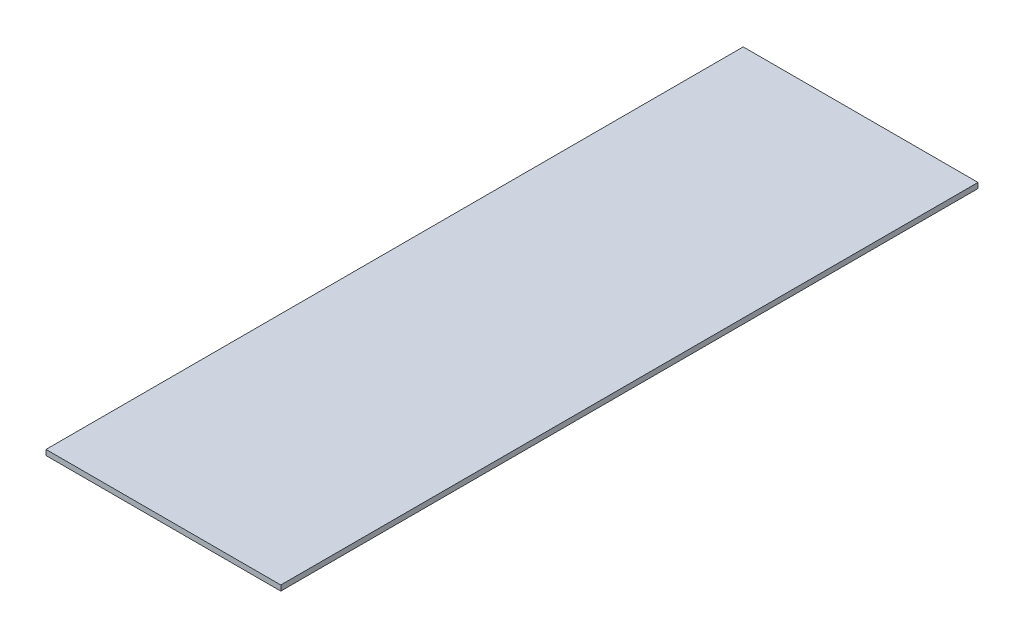
from build123d import *

# Parameters (mm, degrees)
SKETCH1_W           = 1676.4
SKETCH1_H           = 38.1
BOSS_EXTRUDE1_DEPTH = 4978.4


with BuildPart() as part:
    # Sketch1 → Boss-Extrude1 (new body)
    with BuildSketch(Plane.XY):
        with Locations((838.2, 19.05)):
            Rectangle(SKETCH1_W, SKETCH1_H)
    extrude(amount=BOSS_EXTRUDE1_DEPTH)


solid = part.part
